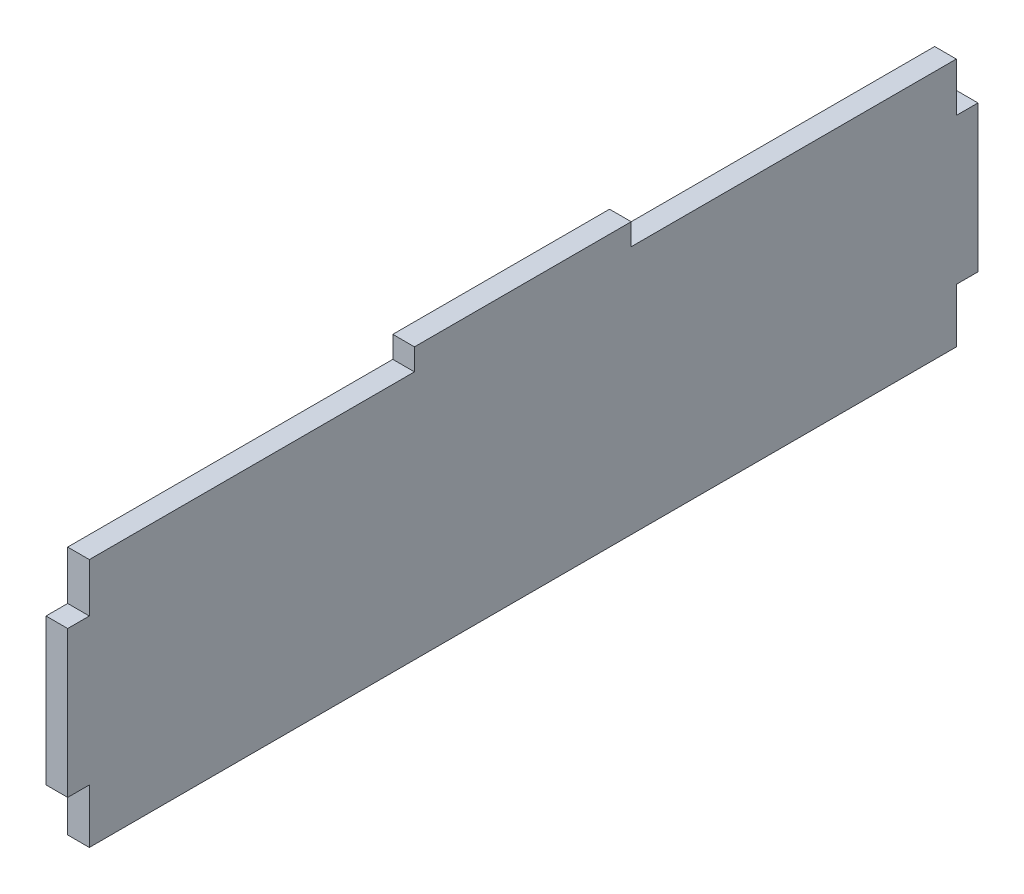
from build123d import *

# Parameters (mm, degrees)
BOSS_EXTRUDE1_DEPTH = 4


with BuildPart() as part:
    # Sketch2 → Boss-Extrude1 (new body)
    with BuildSketch(Plane(origin=(0, 0, 0), x_dir=(0, 0, -1), z_dir=(1, 0, 0))):
        Polygon((61, 3.015400021), (101, 3.015400021), (101, -0.984599979), (161, -0.984599979), (161, -10), (165, -10), (165, -37), (161, -37), (161, -47), (1, -47), (1, -37), (-3, -37), (-3, -10), (1, -10), (1, -0.984599979), (61, -0.984599979), align=None)
    extrude(amount=BOSS_EXTRUDE1_DEPTH)


solid = part.part
